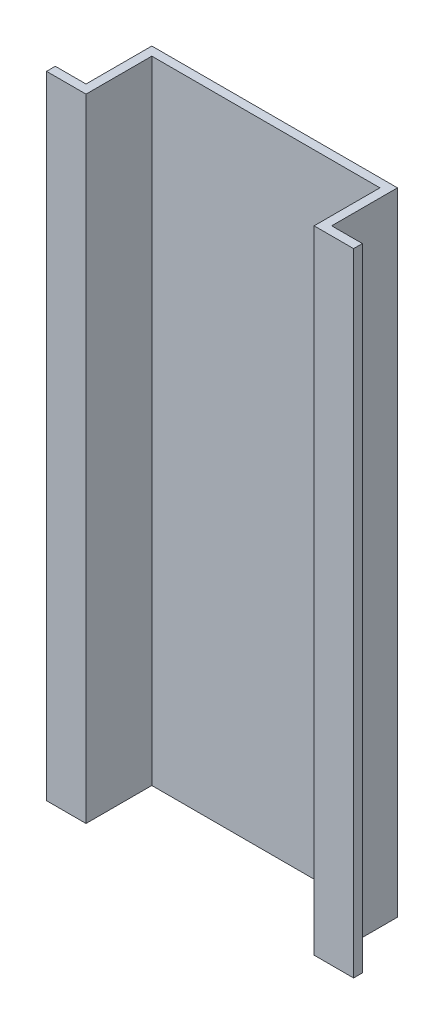
from build123d import *

# Parameters (mm, degrees)
BOSS_EXTRUDE1_DEPTH = 72


with BuildPart() as part:
    # Sketch1 → Boss-Extrude1 (new body)
    with BuildSketch(Plane(origin=(0, 0, 0), x_dir=(1, 0, 0), z_dir=(0, 1, 0))):
        Polygon((0, -0.5), (4.5, -0.5), (4.5, 7), (30.5, 7), (30.5, -0.5), (35, -0.5), (35, 0.5), (31.5, 0.5), (31.5, 8), (3.5, 8), (3.5, 0.5), (0, 0.5), align=None)
    extrude(amount=BOSS_EXTRUDE1_DEPTH)


solid = part.part
